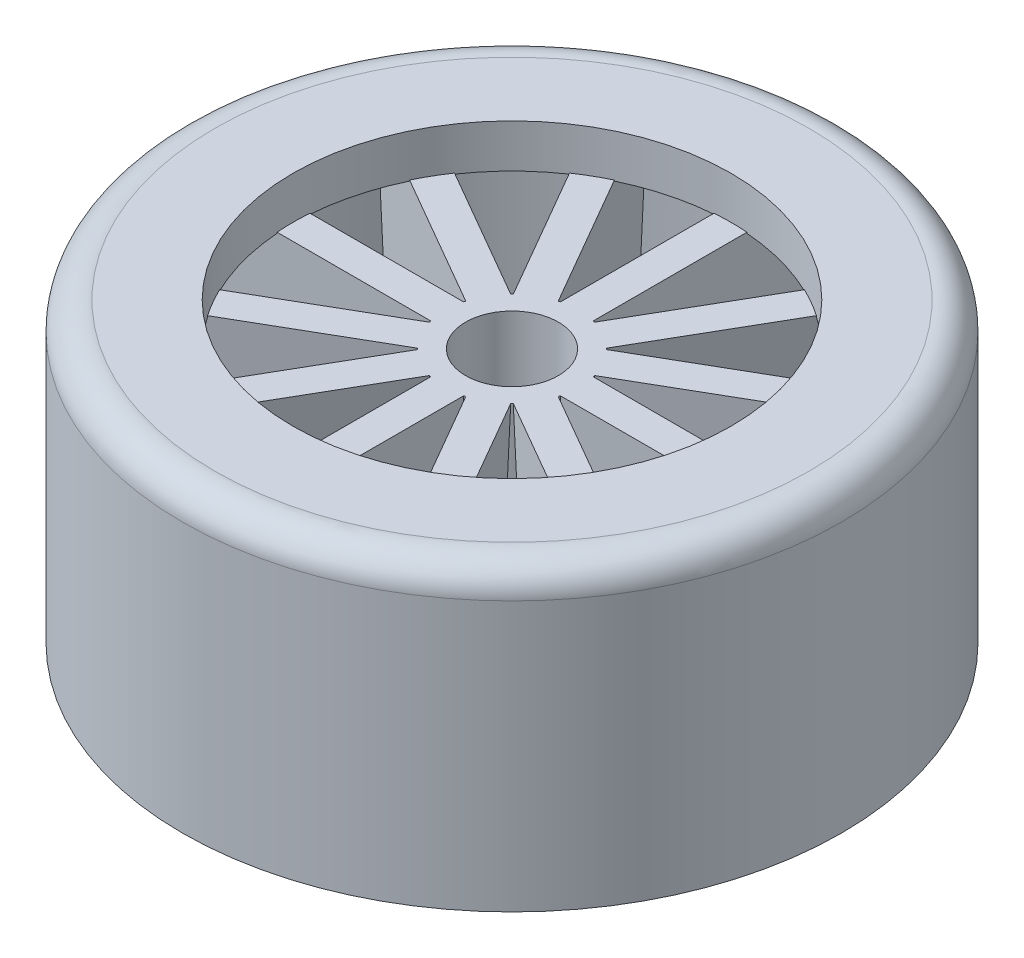
from build123d import *

# Parameters (mm, degrees)
CROQUIS9_W            = 1.2
CROQUIS9_H            = 22.555917484
CROQUIS7_W            = 2.8
CROQUIS7_H            = 21.475484054
MATRIZC1_COUNT        = 12
CROQUIS12_R           = 26.25
CORTAR_EXTRUIR1_DEPTH = 6.27866


with BuildPart() as part:
    # Croquis3 → Revolución1 (revolve)
    with BuildSketch(Plane.XY):
        with BuildLine():
            Line((-18.65, 21.6), (-24.75, 21.6))
            ThreePointArc((-24.75, 21.6), (-25.810660172, 21.160660172), (-26.25, 20.1))
            Line((-26.25, 20.1), (-26.25, 6.3))
            Line((-26.25, 6.3), (-26.25, 0))
            Line((-26.25, 0), (-28.05, 0))
            Line((-28.05, 0), (-28.05, 22.927976992))
            ThreePointArc((-28.05, 22.927976992), (-27.212541818, 24.749641908), (-25.284614111, 25.3))
            Line((-25.284614111, 25.3), (-18.65, 25.3))
            Line((-18.65, 25.3), (-18.65, 21.6))
        make_face()
        Polygon((-5.7, 21.678660446), (-5.55, 6.278660446), (-3.95, 6.278660446), (-3.95, 21.678660446), align=None)
    revolve(axis=Axis((0, 23.529403343, 0), (0, -1, 0)))

    # Croquis9 → Recubrir3 section 0
    with BuildSketch(Plane(origin=(0, 0, 0), x_dir=(1, 0, 0), z_dir=(0, 1, 0))):
        with Locations((0, 16.06775692)):
            Rectangle(CROQUIS9_W, CROQUIS9_H)
    # Croquis7 → Recubrir3 section 1
    with BuildSketch(Plane(origin=(0, 21.678660446, 0), x_dir=(1, 0, 0), z_dir=(0, 1, 0))):
        with Locations((0, 16.144472875)):
            Rectangle(CROQUIS7_W, CROQUIS7_H)
    recubrir3 = loft()

    # MatrizC1: Recubrir3 ×12 about axis
    matrizc1_axis = Axis((0, 0, 0), (0, 1, 0))
    for i in range(1, MATRIZC1_COUNT):
        add(recubrir3.rotate(matrizc1_axis, i * 360 / MATRIZC1_COUNT))

    # Croquis12 → Cortar-Extruir1 (cut)
    with BuildSketch(Plane.XZ):
        Circle(CROQUIS12_R)
    extrude(amount=-CORTAR_EXTRUIR1_DEPTH, mode=Mode.SUBTRACT)


solid = part.part
